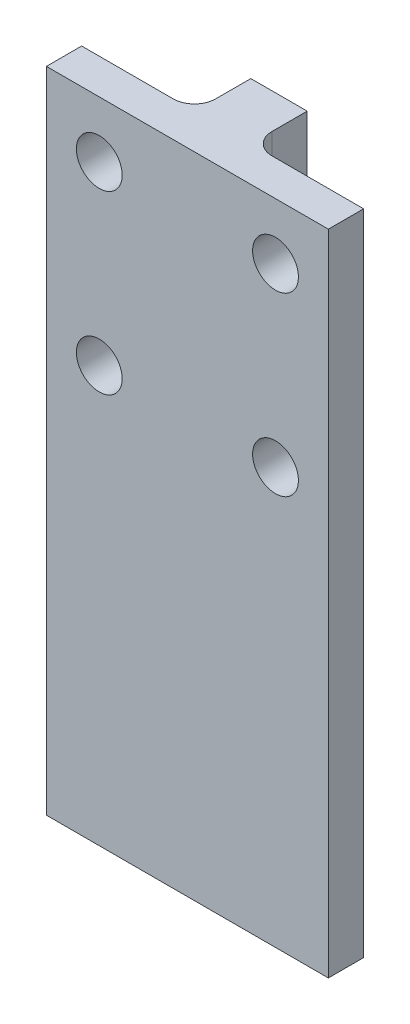
from build123d import *

# Parameters (mm, degrees)
BOSS_EXTRUDE1_DEPTH = 92
FILLET1_R           = 3
SKETCH2_R           = 3.25
CUT_EXTRUDE1_DEPTH  = 92


with BuildPart() as part:
    # Sketch1 → Boss-Extrude1 (new body)
    with BuildSketch(Plane(origin=(0, 0, 0), x_dir=(1, 0, 0), z_dir=(0, 1, 0))):
        Polygon((-4, 5), (-4, 13), (4, 13), (4, 5), (20, 5), (20, 0), (-20, 0), (-20, 5), align=None)
    extrude(amount=-BOSS_EXTRUDE1_DEPTH)

    # Fillet1
    fillet1_edges = [part.edges().sort_by_distance(p)[0] for p in [
        (-4, -46, -5),
        (4, -46, -5),
    ]]
    fillet(fillet1_edges, radius=FILLET1_R)

    # Sketch2 → Cut-Extrude1 (cut)
    with BuildSketch(Plane.XY):
        with Locations((12.5, -8)):
            Circle(SKETCH2_R)
        with Locations((12.5, -33)):
            Circle(SKETCH2_R)
        with Locations((-12.5, -33)):
            Circle(SKETCH2_R)
        with Locations((-12.5, -8)):
            Circle(SKETCH2_R)
    extrude(amount=-CUT_EXTRUDE1_DEPTH, mode=Mode.SUBTRACT)


solid = part.part
